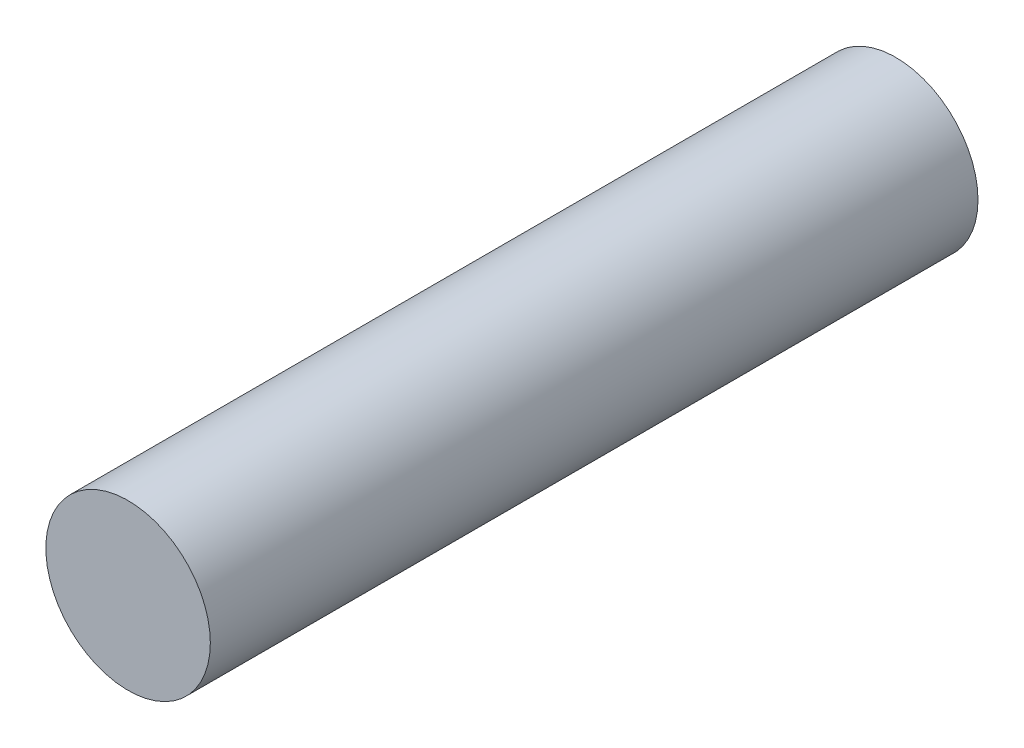
from build123d import *

# Parameters (mm, degrees)
SKETCH1_R           = 4.7625
BOSS_EXTRUDE1_DEPTH = 44.45


with BuildPart() as part:
    # Sketch1 → Boss-Extrude1 (new body)
    with BuildSketch(Plane.XY):
        Circle(SKETCH1_R)
    extrude(amount=BOSS_EXTRUDE1_DEPTH)


solid = part.part
